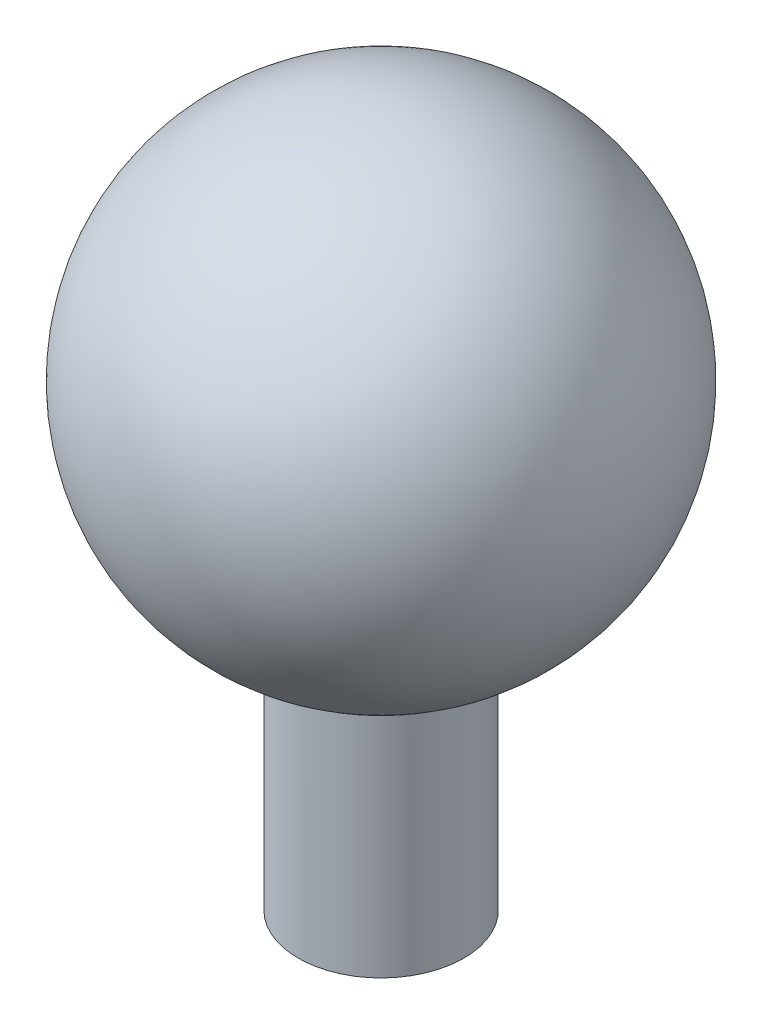
from build123d import *

# Parameters (mm, degrees)
SKETCH_2_R          = 3
CUT_EXTRUDE_1_DEPTH = 48


with BuildPart() as part:
    # 草图1 → 旋转1 (revolve)
    with BuildSketch(Plane.XY):
        with BuildLine():
            Line((0, 0), (0, 58.734993995))
            ThreePointArc((0, 58.734993995), (-19.681207787, 42.291686286), (-7, 20))
            Line((-7, 20), (-7, 0))
            Line((-7, 0), (0, 0))
        make_face()
    revolve(axis=Axis((0, 0, 0), (0, 1, 0)))

    # 草图2 → 切除-拉伸1 (cut)
    with BuildSketch(Plane.XZ):
        Circle(SKETCH_2_R)
    extrude(amount=-CUT_EXTRUDE_1_DEPTH, mode=Mode.SUBTRACT)


solid = part.part
